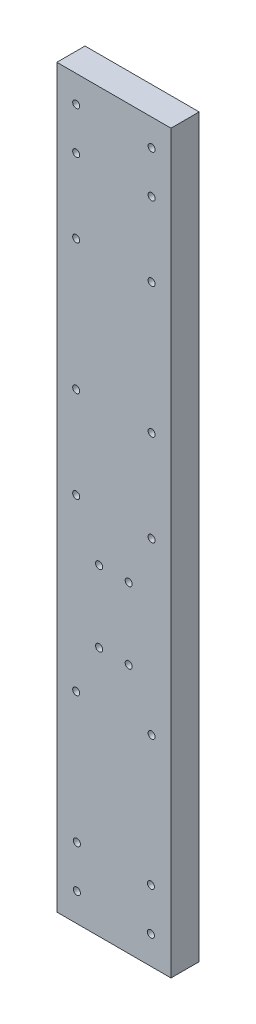
from build123d import *

# Parameters (mm, degrees)
SKETCH1_W           = 16.2
SKETCH1_H           = 104.46
SKETCH1_R           = 0.5
BOSS_EXTRUDE1_DEPTH = 4


with BuildPart() as part:
    # Sketch1 → Boss-Extrude1 (new body)
    with BuildSketch(Plane.XY):
        with Locations((8.1, 52.23)):
            Rectangle(SKETCH1_W, SKETCH1_H)
        with Locations((13.45, 52.64)):
            Circle(SKETCH1_R, mode=Mode.SUBTRACT)
        with Locations((13.45, 94.665)):
            Circle(SKETCH1_R, mode=Mode.SUBTRACT)
        with Locations((2.75, 100.665)):
            Circle(SKETCH1_R, mode=Mode.SUBTRACT)
        with Locations((2.75, 52.64)):
            Circle(SKETCH1_R, mode=Mode.SUBTRACT)
        with Locations((6, 45.64)):
            Circle(SKETCH1_R, mode=Mode.SUBTRACT)
        with Locations((13.45, 28.5)):
            Circle(SKETCH1_R, mode=Mode.SUBTRACT)
        with Locations((6, 35.5)):
            Circle(SKETCH1_R, mode=Mode.SUBTRACT)
        with Locations((2.75, 28.5)):
            Circle(SKETCH1_R, mode=Mode.SUBTRACT)
        with Locations((2.75, 94.665)):
            Circle(SKETCH1_R, mode=Mode.SUBTRACT)
        with Locations((13.45, 84.165)):
            Circle(SKETCH1_R, mode=Mode.SUBTRACT)
        with Locations((13.45, 65.64)):
            Circle(SKETCH1_R, mode=Mode.SUBTRACT)
        with Locations((13.45, 100.665)):
            Circle(SKETCH1_R, mode=Mode.SUBTRACT)
        with Locations((10.2, 45.64)):
            Circle(SKETCH1_R, mode=Mode.SUBTRACT)
        with Locations((2.75, 84.165)):
            Circle(SKETCH1_R, mode=Mode.SUBTRACT)
        with Locations((2.85, 10)):
            Circle(SKETCH1_R, mode=Mode.SUBTRACT)
        with Locations((13.35, 10)):
            Circle(SKETCH1_R, mode=Mode.SUBTRACT)
        with Locations((13.35, 4)):
            Circle(SKETCH1_R, mode=Mode.SUBTRACT)
        with Locations((2.85, 4)):
            Circle(SKETCH1_R, mode=Mode.SUBTRACT)
        with Locations((2.75, 65.64)):
            Circle(SKETCH1_R, mode=Mode.SUBTRACT)
        with Locations((10.2, 35.5)):
            Circle(SKETCH1_R, mode=Mode.SUBTRACT)
    extrude(amount=BOSS_EXTRUDE1_DEPTH)


solid = part.part
